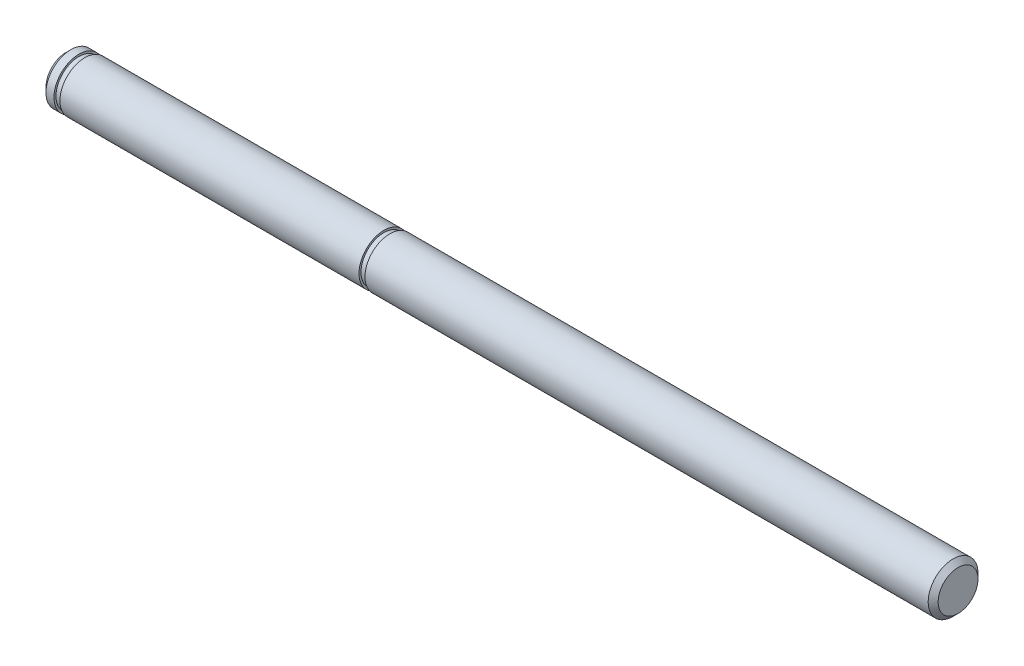
from build123d import *

# Parameters (mm, degrees)
SKETCH2_R           = 3.175
BOSS_EXTRUDE1_DEPTH = 113.665
CHAMFER1_SIZE       = 0.635
SKETCH3_W           = 0.762
SKETCH3_H           = 0.254


with BuildPart() as part:
    # Sketch2 → Boss-Extrude1 (new body)
    with BuildSketch(Plane(origin=(0, 0, 0), x_dir=(0, 0, -1), z_dir=(1, 0, 0))):
        Circle(SKETCH2_R)
    extrude(amount=BOSS_EXTRUDE1_DEPTH)

    # Chamfer1
    chamfer1_edges = [part.edges().sort_by_distance(p)[0] for p in [
        (0, 0, 3.175),
        (113.665, 0, 3.175),
    ]]
    chamfer(chamfer1_edges, length=CHAMFER1_SIZE)

    # Sketch3 → Cut-Revolve1 (revolve, cut)
    with BuildSketch(Plane.XY):
        with Locations((2.032, 3.048)):
            Rectangle(SKETCH3_W, SKETCH3_H)
        with Locations((40.894, 3.048)):
            Rectangle(SKETCH3_W, SKETCH3_H)
    revolve(axis=Axis((0, 0, 0), (1, 0, 0)), mode=Mode.SUBTRACT)


solid = part.part
